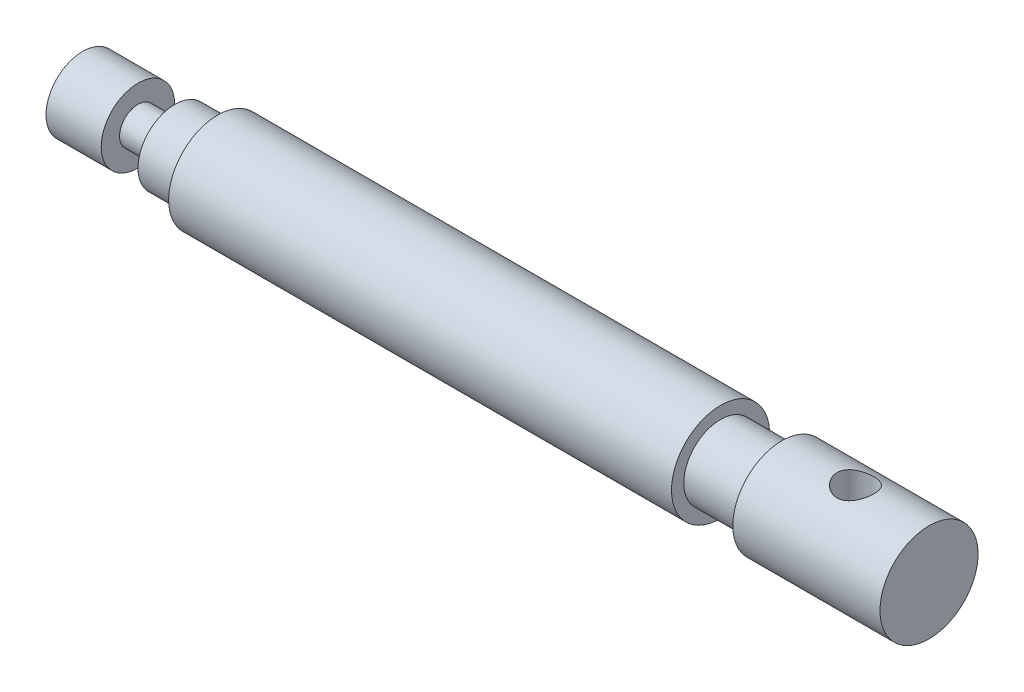
from build123d import *

# Parameters (mm, degrees)
CUT_EXTRUDE1_REACH = 18
SKETCH3_R          = 3


with BuildPart() as part:
    # Sketch1 → Revolve1 (revolve)
    with BuildSketch(Plane(origin=(0, 0, 0), x_dir=(1, 0, 0), z_dir=(0, 1, 0))):
        Polygon((-54.771838843, 0), (-54.771838843, 6), (-45.771838843, 6), (-45.771838843, 3), (-39.771838843, 3), (-39.771838843, 6), (-32.771838843, 6), (-32.771838843, 8), (49.228161157, 8), (49.228161157, 6), (59.228161157, 6), (59.228161157, 8), (83.228161157, 8), (83.228161157, 0), align=None)
    revolve(axis=Axis((-54.771838843, 0, 0), (1, 0, 0)))

    # Sketch3 → Cut-Extrude1 (cut, up to next)
    with BuildSketch(Plane(origin=(0, 8, 0), x_dir=(1, 0, 0), z_dir=(0, 1, 0)), mode=Mode.PRIVATE) as cut_extrude1_sk1:
        with Locations((71.228161157, 0)):
            Circle(SKETCH3_R)
    cut_extrude1_tool1 = extrude(cut_extrude1_sk1.sketch, amount=-CUT_EXTRUDE1_REACH, mode=Mode.PRIVATE) & part.part
    add(cut_extrude1_tool1.solids().sort_by_distance((71.228161, 8, 0))[0], mode=Mode.SUBTRACT)


solid = part.part
